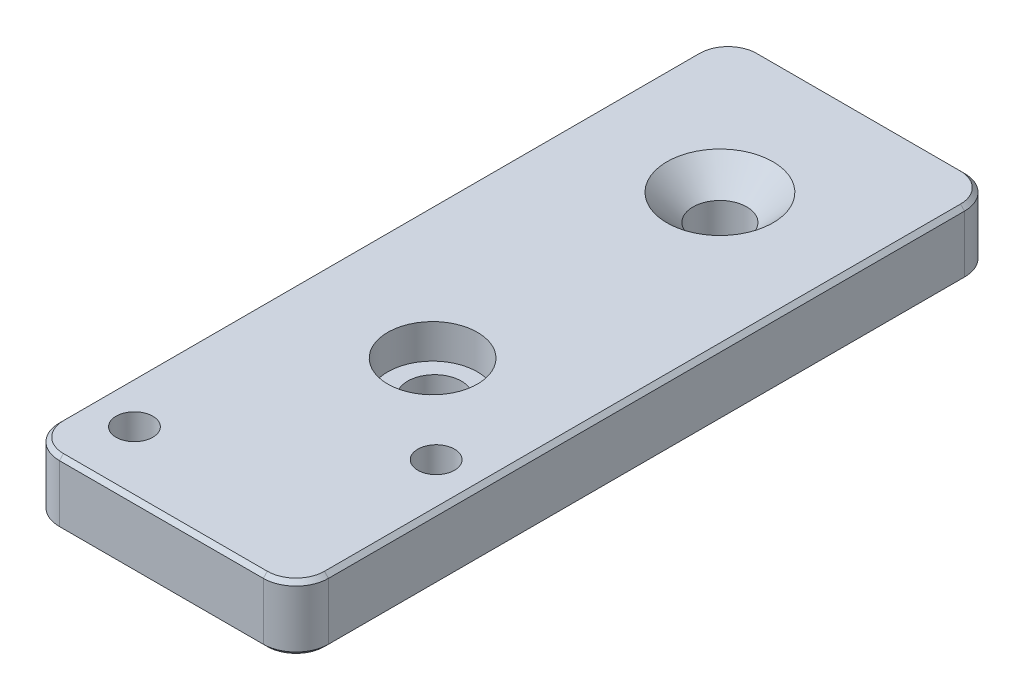
from build123d import *

# Parameters (mm, degrees)
SKETCH3_W           = 33
SKETCH3_H           = 86
SKETCH3_R           = 3.3
SKETCH3_R_2         = 2.25
BOSS_EXTRUDE2_DEPTH = 8
SKETCH4_R           = 5.5
CUT_EXTRUDE2_DEPTH  = 4.2
CHAMFER1_SIZE       = 3.2
SKETCH5_R           = 4
CUT_EXTRUDE3_DEPTH  = 4.4
FILLET1_R           = 4
CHAMFER2_SIZE       = 0.5


with BuildPart() as part:
    # Sketch3 → Boss-Extrude2 (new body)
    with BuildSketch(Plane(origin=(0, 0, 0), x_dir=(1, 0, 0), z_dir=(0, 1, 0))):
        Rectangle(SKETCH3_W, SKETCH3_H)
        with Locations((0, 25.5)):
            Circle(SKETCH3_R, mode=Mode.SUBTRACT)
        with Locations((0, -9.5)):
            Circle(SKETCH3_R, mode=Mode.SUBTRACT)
        with Locations((11, -20.3)):
            Circle(SKETCH3_R_2, mode=Mode.SUBTRACT)
        with Locations((-11, -35.3)):
            Circle(SKETCH3_R_2, mode=Mode.SUBTRACT)
    extrude(amount=BOSS_EXTRUDE2_DEPTH)

    # Sketch4 → Cut-Extrude2 (cut)
    with BuildSketch(Plane(origin=(0, 8, 0), x_dir=(1, 0, 0), z_dir=(0, 1, 0))):
        with Locations((0, -9.736308316)):
            Circle(SKETCH4_R)
    extrude(amount=-CUT_EXTRUDE2_DEPTH, mode=Mode.SUBTRACT)

    # Chamfer1
    chamfer1_edges = [part.edges().sort_by_distance(p)[0] for p in [
        (-3.3, 8, -25.5),
    ]]
    chamfer(chamfer1_edges, length=CHAMFER1_SIZE)

    # Sketch5 → Cut-Extrude3 (cut)
    with BuildSketch(Plane(origin=(0, 0, 0), x_dir=(-1, 0, 0), z_dir=(0, -1, 0))):
        with Locations((11, -35.3)):
            Circle(SKETCH5_R)
        with Locations((-11, -20.3)):
            Circle(SKETCH5_R)
    extrude(amount=-CUT_EXTRUDE3_DEPTH, mode=Mode.SUBTRACT)

    # Fillet1
    fillet1_edges = [part.edges().sort_by_distance(p)[0] for p in [
        (16.5, 4, 43),
        (-16.5, 4, 43),
        (-16.5, 4, -43),
        (16.5, 4, -43),
    ]]
    fillet(fillet1_edges, radius=FILLET1_R)

    # Chamfer2
    chamfer2_edges = [part.edges().sort_by_distance(p)[0] for p in [
        (16.5, 0, 0),
        (16.5, 8, 0),
        (0, 0, 43),
        (-16.5, 0, 0),
        (0, 0, -43),
        (15.328427125, 0, -41.828427125),
        (-15.328427125, 0, -41.828427125),
        (-15.328427125, 0, 41.828427125),
        (15.328427125, 0, 41.828427125),
        (0, 8, 43),
        (0, 8, -43),
        (-16.5, 8, 0),
        (15.328427125, 8, -41.828427125),
        (-15.328427125, 8, -41.828427125),
        (-15.328427125, 8, 41.828427125),
        (15.328427125, 8, 41.828427125),
    ]]
    chamfer(chamfer2_edges, length=CHAMFER2_SIZE)


solid = part.part
